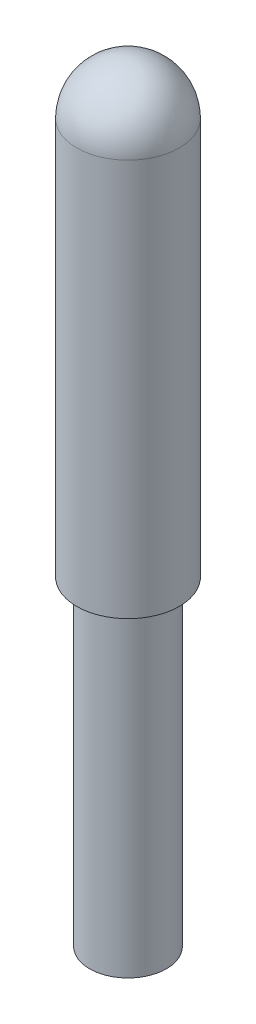
from build123d import *

# Parameters (mm, degrees)
SKETCH1_R           = 4
BOSS_EXTRUDE1_DEPTH = 35
SKETCH1_3_R         = 3
BOSS_EXTRUDE2_DEPTH = 25
FILLET1_R           = 4


with BuildPart() as part:
    # Sketch1 → Boss-Extrude1 (new body)
    with BuildSketch(Plane(origin=(0, 0, 0), x_dir=(1, 0, 0), z_dir=(0, 1, 0))):
        Circle(SKETCH1_R)
    extrude(amount=BOSS_EXTRUDE1_DEPTH)

    # Sketch1_3 → Boss-Extrude2 (add)
    with BuildSketch(Plane(origin=(0, 0, 0), x_dir=(1, 0, 0), z_dir=(0, 1, 0))):
        Circle(SKETCH1_3_R)
    extrude(amount=-BOSS_EXTRUDE2_DEPTH)

    # Fillet1
    fillet1_edges = [part.edges().sort_by_distance(p)[0] for p in [
        (-4, 35, 0),
    ]]
    fillet(fillet1_edges, radius=FILLET1_R)


solid = part.part
